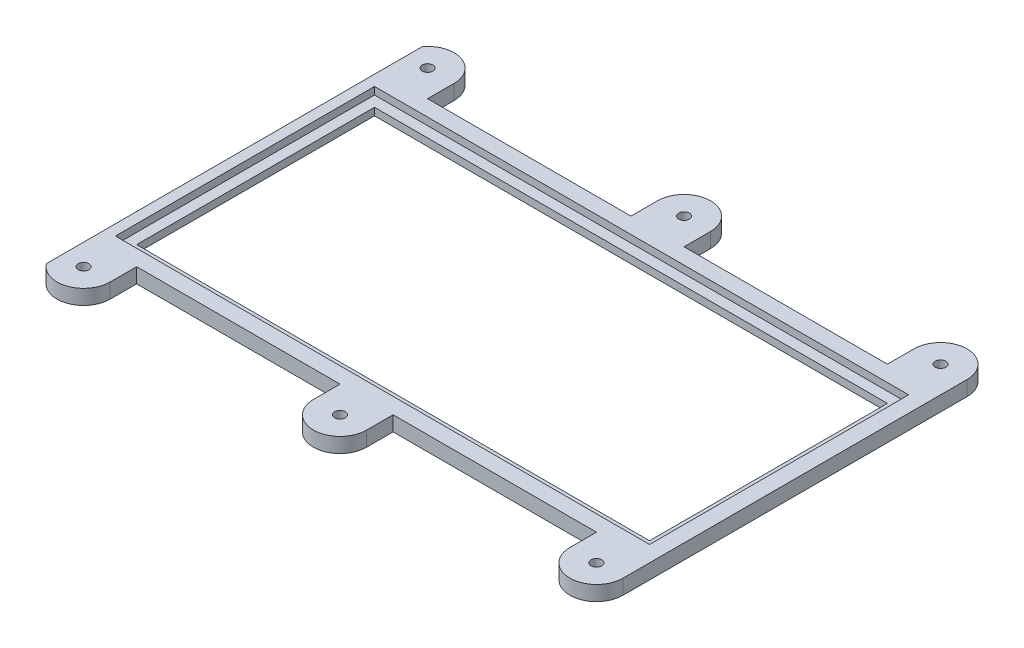
from build123d import *

# Parameters (mm, degrees)
SKETCH1_W               = 53.3
SKETCH1_H               = 27.4
SKETCH1_W_2             = 48.3
SKETCH1_H_2             = 22.4
BOSS_EXTRUDE1_DEPTH     = 0.7
SKETCH2_W               = 53.3
SKETCH2_H               = 27.4
SKETCH2_W_2             = 50.3
SKETCH2_H_2             = 24.4
BOSS_EXTRUDE2_DEPTH     = 0.7
SKETCH3_R               = 0.5
BOSS_EXTRUDE3_DEPTH     = 1.4
SKETCH5_W               = 13.547692857
SKETCH5_H               = 47.955685723
CUT_EXTRUDE1_DEPTH      = 1
CUT_EXTRUDE1_DEPTH_BACK = 2.4


with BuildPart() as part:
    # Sketch1 → Boss-Extrude1 (new body)
    with BuildSketch(Plane(origin=(0, 0, 0), x_dir=(1, 0, 0), z_dir=(0, 1, 0))):
        Rectangle(SKETCH1_W, SKETCH1_H)
        Rectangle(SKETCH1_W_2, SKETCH1_H_2, mode=Mode.SUBTRACT)
    extrude(amount=BOSS_EXTRUDE1_DEPTH)

    # Sketch2 → Boss-Extrude2 (add)
    with BuildSketch(Plane(origin=(0, 0.7, 0), x_dir=(1, 0, 0), z_dir=(0, 1, 0))):
        Rectangle(SKETCH2_W, SKETCH2_H)
        Rectangle(SKETCH2_W_2, SKETCH2_H_2, mode=Mode.SUBTRACT)
    extrude(amount=BOSS_EXTRUDE2_DEPTH)

    # Sketch3 → Boss-Extrude3 (add)
    with BuildSketch(Plane.XZ):
        with BuildLine():
            Line((-26.65, 13.7), (-21.65, 13.7))
            Line((-21.65, 13.7), (-21.65, 16.2))
            ThreePointArc((-21.65, 16.2), (-24.15, 18.7), (-26.65, 16.2))
            Line((-26.65, 16.2), (-26.65, 13.7))
        make_face()
        with Locations((-24.15, 16.2)):
            Circle(SKETCH3_R, mode=Mode.SUBTRACT)
        with BuildLine():
            Line((26.65, 16.2), (26.65, 13.7))
            Line((26.65, 13.7), (21.65, 13.7))
            Line((21.65, 13.7), (21.65, 16.2))
            ThreePointArc((21.65, 16.2), (24.15, 18.7), (26.65, 16.2))
        make_face()
        with Locations((24.15, 16.2)):
            Circle(SKETCH3_R, mode=Mode.SUBTRACT)
        with BuildLine():
            Line((2.5, 16.2), (2.5, 13.7))
            Line((2.5, 13.7), (-2.5, 13.7))
            Line((-2.5, 13.7), (-2.5, 16.2))
            ThreePointArc((-2.5, 16.2), (0, 18.7), (2.5, 16.2))
        make_face()
        with Locations((0, 16.2)):
            Circle(SKETCH3_R, mode=Mode.SUBTRACT)
    boss_extrude3 = extrude(amount=-BOSS_EXTRUDE3_DEPTH)

    # Mirror1: Boss-Extrude3 across plane
    add(boss_extrude3.mirror(Plane.XY))

    # Sketch5 → Cut-Extrude1 (cut, two sides)
    with BuildSketch(Plane(origin=(0, 1.4, 0), x_dir=(1, 0, 0), z_dir=(0, 1, 0))) as cut_extrude1_sk:
        with Locations((-32.923846428, 2.960560152)):
            Rectangle(SKETCH5_W, SKETCH5_H)
    extrude(amount=CUT_EXTRUDE1_DEPTH, mode=Mode.SUBTRACT)
    extrude(cut_extrude1_sk.sketch, amount=-CUT_EXTRUDE1_DEPTH_BACK, mode=Mode.SUBTRACT)


solid = part.part
